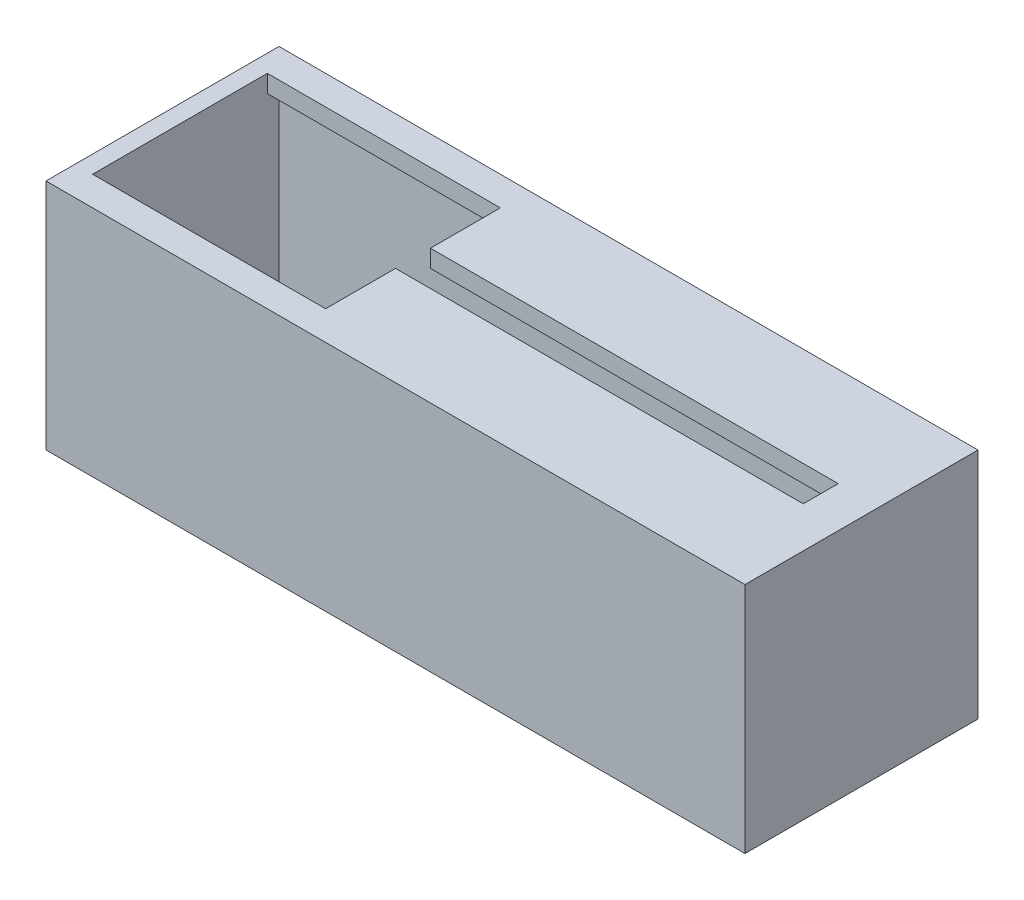
from build123d import *

# Parameters (mm, degrees)
CROQUIS1_W              = 60
CROQUIS1_H              = 20
SALIENTE_EXTRUIR1_DEPTH = 20
VACIADO1_T              = 1.5
CORTAR_EXTRUIR1_DEPTH   = 18
CROQUIS3_R              = 1.25
CORTAR_EXTRUIR2_DEPTH   = 2.5


with BuildPart() as part:
    # Croquis1 → Saliente-Extruir1 (new body)
    with BuildSketch(Plane(origin=(0, 0, 0), x_dir=(1, 0, 0), z_dir=(0, 1, 0))):
        with Locations((30, -10)):
            Rectangle(CROQUIS1_W, CROQUIS1_H)
    extrude(amount=SALIENTE_EXTRUIR1_DEPTH)

    # Vaciado1 (no face opened: a closed hollow body)
    add(offset(amount=-VACIADO1_T, mode=Mode.PRIVATE), mode=Mode.SUBTRACT)

    # Croquis2 → Cortar-Extruir1 (cut)
    with BuildSketch(Plane(origin=(0, 20, 0), x_dir=(1, 0, 0), z_dir=(0, 1, 0))):
        Polygon((1.5, -2.5), (21.5, -2.5), (21.5, -8.5), (56.5, -8.5), (56.5, -11.5), (21.5, -11.5), (21.5, -17.5), (1.5, -17.5), align=None)
    extrude(amount=-CORTAR_EXTRUIR1_DEPTH, mode=Mode.SUBTRACT)

    # Croquis3 → Cortar-Extruir2 (cut, through all)
    with BuildSketch(Plane(origin=(0, 1.5, 0), x_dir=(1, 0, 0), z_dir=(0, 1, 0))):
        with Locations(Location((4, -10.25, 0), (0, 0, 270))):  # turned: the seam where the file's is
            Circle(CROQUIS3_R)
    extrude(amount=-CORTAR_EXTRUIR2_DEPTH, mode=Mode.SUBTRACT)


solid = part.part
